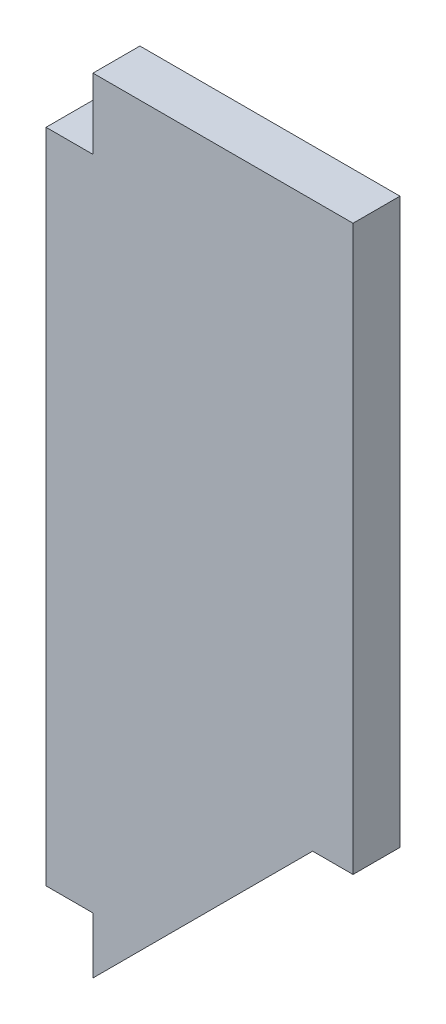
from build123d import *

# Parameters (mm, degrees)
BOSS_EXTRUDE1_DEPTH = 12.7
SKETCH2_W           = 12.7
SKETCH2_H           = 19.05
CUT_EXTRUDE1_DEPTH  = 13.7


with BuildPart() as part:
    # Sketch1 → Boss-Extrude1 (new body)
    with BuildSketch(Plane.XY):
        Polygon((0, -215.9), (8.89, -215.9), (72.148675035, -152.641324965), (83.080541238, -152.641324965), (83.080541238, 0), (76.730541238, 0), (0, 0), align=None)
    extrude(amount=BOSS_EXTRUDE1_DEPTH)

    # Sketch2 → Cut-Extrude1 (cut, through all)
    with BuildSketch(Plane.XY.offset(12.7)):
        with Locations((6.35, -9.525)):
            Rectangle(SKETCH2_W, SKETCH2_H)
        with Locations((6.35, -206.375)):
            Rectangle(SKETCH2_W, SKETCH2_H)
    extrude(amount=-CUT_EXTRUDE1_DEPTH, mode=Mode.SUBTRACT)


solid = part.part
